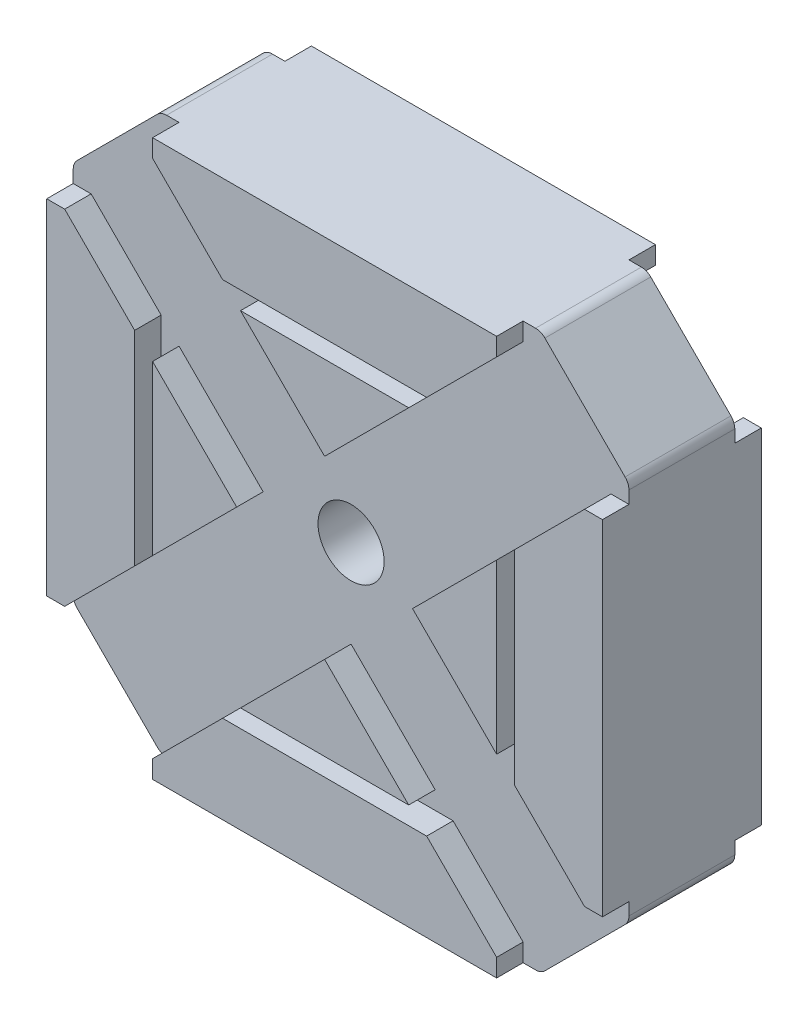
from build123d import *

# Parameters (mm, degrees)
BOSS_EXTRUDE1_DEPTH = 6
SKETCH2_W           = 1.355339059
SKETCH2_H           = 2
CUT_EXTRUDE1_DEPTH  = 43
SKETCH3_W           = 2
SKETCH3_H           = 1.355339059
CUT_EXTRUDE2_DEPTH  = 43
SKETCH4_W           = 2
SKETCH4_H           = 9.39696962
CUT_EXTRUDE3_DEPTH  = 55.69848481
SKETCH5_W           = 2
SKETCH5_H           = 9.39696962
CUT_EXTRUDE4_DEPTH  = 55.69848481
SKETCH7_R           = 2.5
CUT_EXTRUDE7_DEPTH  = 7
FILLET1_R           = 1


with BuildPart() as part:
    # Sketch1 → Boss-Extrude1 (new body)
    with BuildSketch(Plane.XY):
        Polygon((-21, 14.355339059), (-14.355339059, 21), (14.355339059, 21), (21, 14.355339059), (21, -14.355339059), (14.355339059, -21), (-14.355339059, -21), (-21, -14.355339059), align=None)
    boss_extrude1 = extrude(amount=BOSS_EXTRUDE1_DEPTH)

    # Sketch2 → Cut-Extrude1 (cut, through all)
    with BuildSketch(Plane(origin=(0, 21, 0), x_dir=(1, 0, 0), z_dir=(0, 1, 0))):
        with Locations((-13.67766953, -1)):
            Rectangle(SKETCH2_W, SKETCH2_H)
        with Locations((13.67766953, -1)):
            Rectangle(SKETCH2_W, SKETCH2_H)
    cut_extrude1 = extrude(amount=-CUT_EXTRUDE1_DEPTH, mode=Mode.SUBTRACT)

    # Sketch3 → Cut-Extrude2 (cut, through all)
    with BuildSketch(Plane.ZY.offset(21)):
        with Locations((1, 13.67766953)):
            Rectangle(SKETCH3_W, SKETCH3_H)
        with Locations((1, -13.67766953)):
            Rectangle(SKETCH3_W, SKETCH3_H)
    cut_extrude2 = extrude(amount=-CUT_EXTRUDE2_DEPTH, mode=Mode.SUBTRACT)

    # Sketch4 → Cut-Extrude3 (cut, through all)
    with BuildSketch(Plane(origin=(17.67766953, 17.67766953, 0), x_dir=(0, 0, -1), z_dir=(0.707106781, 0.707106781, 0))):
        with Locations((-1, 0)):
            Rectangle(SKETCH4_W, SKETCH4_H)
    cut_extrude3 = extrude(amount=-CUT_EXTRUDE3_DEPTH, mode=Mode.SUBTRACT)

    # Sketch5 → Cut-Extrude4 (cut, through all)
    with BuildSketch(Plane(origin=(-17.67766953, 17.67766953, 0), x_dir=(0, 0, 1), z_dir=(-0.707106781, 0.707106781, 0))):
        with Locations((1, 0)):
            Rectangle(SKETCH5_W, SKETCH5_H)
    cut_extrude4 = extrude(amount=-CUT_EXTRUDE4_DEPTH, mode=Mode.SUBTRACT)

    # Sketch7 → Cut-Extrude7 (cut, through all)
    with BuildSketch(Plane(origin=(0, 0, 0), x_dir=(-1, 0, 0), z_dir=(0, 0, -1))):
        Circle(SKETCH7_R)
    cut_extrude7 = extrude(amount=-CUT_EXTRUDE7_DEPTH, mode=Mode.SUBTRACT)

    # Mirror2: Boss-Extrude1, Cut-Extrude1, Cut-Extrude2, Cut-Extrude3, Cut-Extrude4, Cut-Extrude7 across plane
    add(boss_extrude1.mirror(Plane(origin=(0, 0, 6), x_dir=(1, 0, 0), z_dir=(0, 0, -1))))
    add(cut_extrude1.mirror(Plane(origin=(0, 0, 6), x_dir=(1, 0, 0), z_dir=(0, 0, -1))), mode=Mode.SUBTRACT)
    add(cut_extrude2.mirror(Plane(origin=(0, 0, 6), x_dir=(1, 0, 0), z_dir=(0, 0, -1))), mode=Mode.SUBTRACT)
    add(cut_extrude3.mirror(Plane(origin=(0, 0, 6), x_dir=(1, 0, 0), z_dir=(0, 0, -1))), mode=Mode.SUBTRACT)
    add(cut_extrude4.mirror(Plane(origin=(0, 0, 6), x_dir=(1, 0, 0), z_dir=(0, 0, -1))), mode=Mode.SUBTRACT)
    add(cut_extrude7.mirror(Plane(origin=(0, 0, 6), x_dir=(1, 0, 0), z_dir=(0, 0, -1))), mode=Mode.SUBTRACT)

    # Fillet1
    fillet1_edges = [part.edges().sort_by_distance(p)[0] for p in [
        (-14.355339059, 21, 6),
        (-14.355339059, -21, 6),
        (14.355339059, 21, 6),
        (14.355339059, -21, 6),
        (-21, 14.355339059, 6),
        (21, 14.355339059, 6),
        (21, -14.355339059, 6),
        (-21, -14.355339059, 6),
    ]]
    fillet(fillet1_edges, radius=FILLET1_R)


solid = part.part
